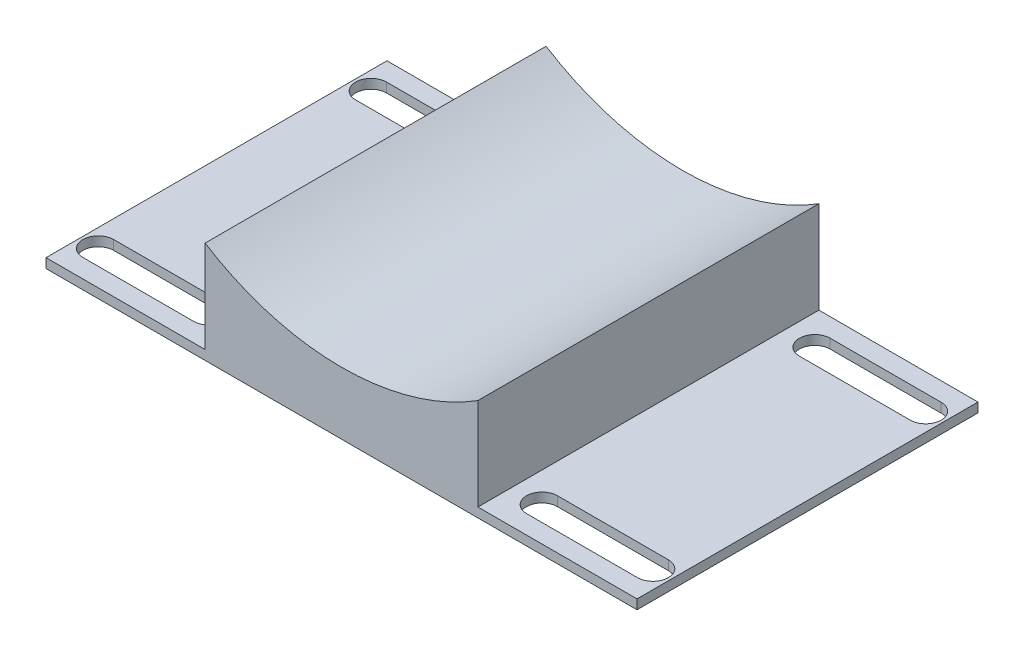
from build123d import *

# Parameters (mm, degrees)
BOSS_EXTRUDE1_DEPTH = 95.25
CUT_EXTRUDE1_DEPTH  = 95.25


with BuildPart() as part:
    # Sketch2 → Boss-Extrude1 (new body)
    with BuildSketch(Plane.XY):
        with BuildLine():
            Line((38.1, 1.3208), (82.55, 1.3208))
            Line((82.55, 1.3208), (82.55, -1.3208))
            Line((82.55, -1.3208), (-82.55, -1.3208))
            Line((-82.55, -1.3208), (-82.55, 1.3208))
            Line((-82.55, 1.3208), (-38.1, 1.3208))
            Line((-38.1, 1.3208), (-38.1, 27.074795193))
            ThreePointArc((-38.1, 27.074795193), (0, 16.0782), (38.1, 27.074795193))
            Line((38.1, 27.074795193), (38.1, 1.3208))
        make_face()
    extrude(amount=BOSS_EXTRUDE1_DEPTH)

    # Sketch3 → Cut-Extrude1 (cut)
    with BuildSketch(Plane(origin=(0, 1.3208, 0), x_dir=(1, 0, 0), z_dir=(0, 1, 0))):
        with BuildLine():
            Line((-77.47, -5.207), (-46.482, -5.207))
            ThreePointArc((-46.482, -5.207), (-42.164, -9.525), (-46.482, -13.843))
            Line((-46.482, -13.843), (-77.47, -13.843))
            ThreePointArc((-77.47, -13.843), (-81.788, -9.525), (-77.47, -5.207))
        make_face()
        with BuildLine():
            Line((-77.47, -81.407), (-46.482, -81.407))
            ThreePointArc((-46.482, -81.407), (-42.164, -85.725), (-46.482, -90.043))
            Line((-46.482, -90.043), (-77.47, -90.043))
            ThreePointArc((-77.47, -90.043), (-81.788, -85.725), (-77.47, -81.407))
        make_face()
    cut_extrude1 = extrude(amount=-CUT_EXTRUDE1_DEPTH, mode=Mode.SUBTRACT)

    # Mirror2: Cut-Extrude1 across plane
    add(cut_extrude1.mirror(Plane(origin=(0, 0, 0), x_dir=(0, 0, 1), z_dir=(1, 0, 0))), mode=Mode.SUBTRACT)


solid = part.part
